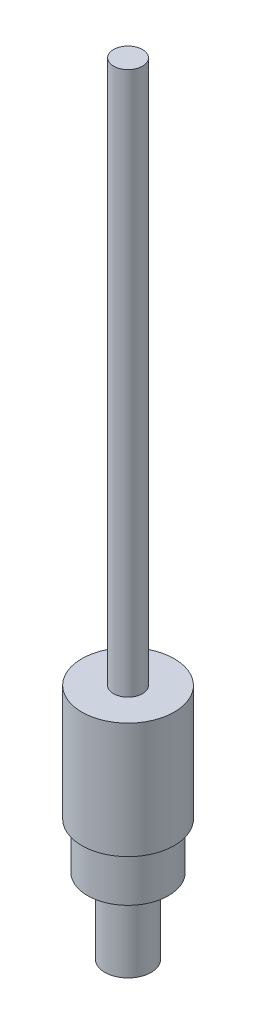
from build123d import *


with BuildPart() as part:
    # Croquis1 → Revolución1 (revolve)
    with BuildSketch(Plane.XY):
        Polygon((0, 0), (-4, 0), (-4, 13), (-7, 13), (-7, 21), (-8, 21), (-8, 41), (-2.5, 41), (-2.5, 135), (0, 135), align=None)
    revolve(axis=Axis((0, 0, 0), (0, 1, 0)))


solid = part.part
